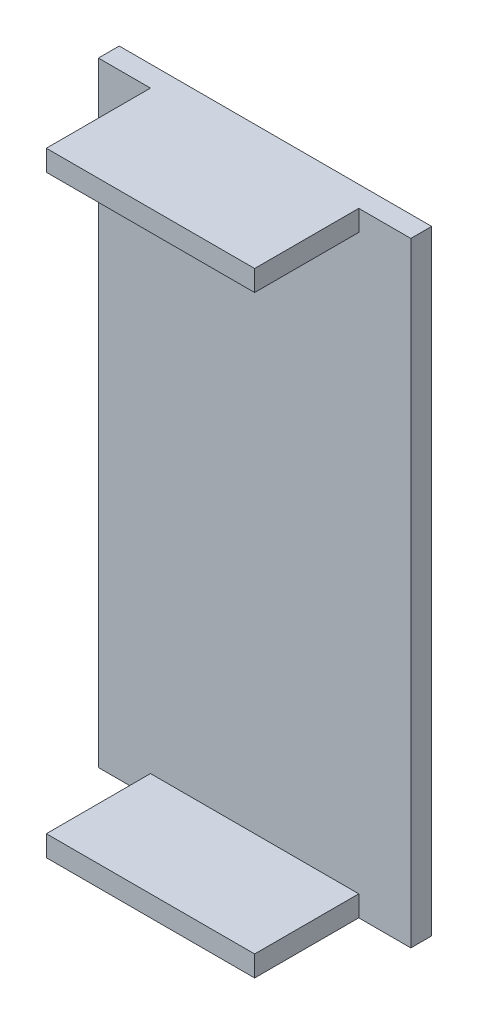
from build123d import *

# Parameters (mm, degrees)
SKETCH1_W           = 30
SKETCH1_H           = 59
BOSS_EXTRUDE1_DEPTH = 2
SKETCH2_W           = 20
SKETCH2_H           = 2
BOSS_EXTRUDE2_DEPTH = 10


with BuildPart() as part:
    # Sketch1 → Boss-Extrude1 (new body)
    with BuildSketch(Plane.XY):
        with Locations((15, 29.5)):
            Rectangle(SKETCH1_W, SKETCH1_H)
    extrude(amount=BOSS_EXTRUDE1_DEPTH)

    # Sketch2 → Boss-Extrude2 (add)
    with BuildSketch(Plane.XY.offset(2)):
        with Locations((15, 58)):
            Rectangle(SKETCH2_W, SKETCH2_H)
        with Locations((15, 1)):
            Rectangle(SKETCH2_W, SKETCH2_H)
    extrude(amount=BOSS_EXTRUDE2_DEPTH)


solid = part.part
